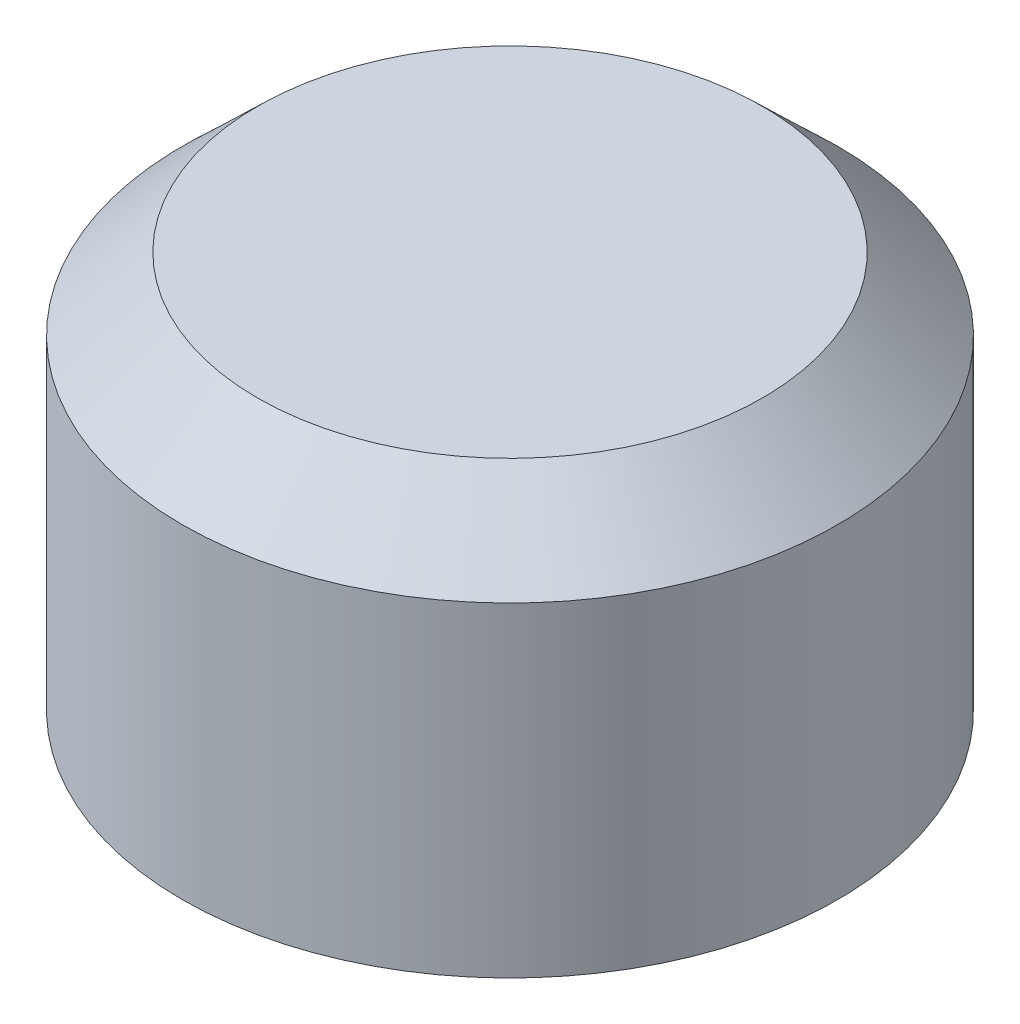
from build123d import *


with BuildPart() as part:
    # Sketch1 → Revolve1 (revolve)
    with BuildSketch(Plane.XY):
        Polygon((-2438.4, 0), (-2438.4, 2753.721024484), (-2118.721024484, 3073.4), (-1190.8772065, 3073.4), (-914.4, 2796.9227935), (-914.4, 2074), (-766.990618326, 1523.86069808), (-792.390618326, 1523.86069808), (-939.8, 2074), (-939.8, 2786.401769016), (-1201.398230984, 3048), (-2108.2, 3048), (-2413, 2743.2), (-2413, 0), align=None)
    revolve(axis=Axis((0, 3520.44, 0), (0, -1, 0)))


with BuildPart() as body_2:
    # Sketch2 → Revolve2 (revolve)
    with BuildSketch(Plane.XY):
        Polygon((-2743.2, 0), (-2768.6, 0), (-2768.6, 2743.2), (-2133.6, 3352.8), (0, 3352.8), (0, 3327.4), (-2123.381318695, 3327.4), (-2743.2, 2732.374065947), align=None)
    revolve(axis=Axis((0, 3520.44, 0), (0, -1, 0)))


solid = Compound([part.part, body_2.part])
